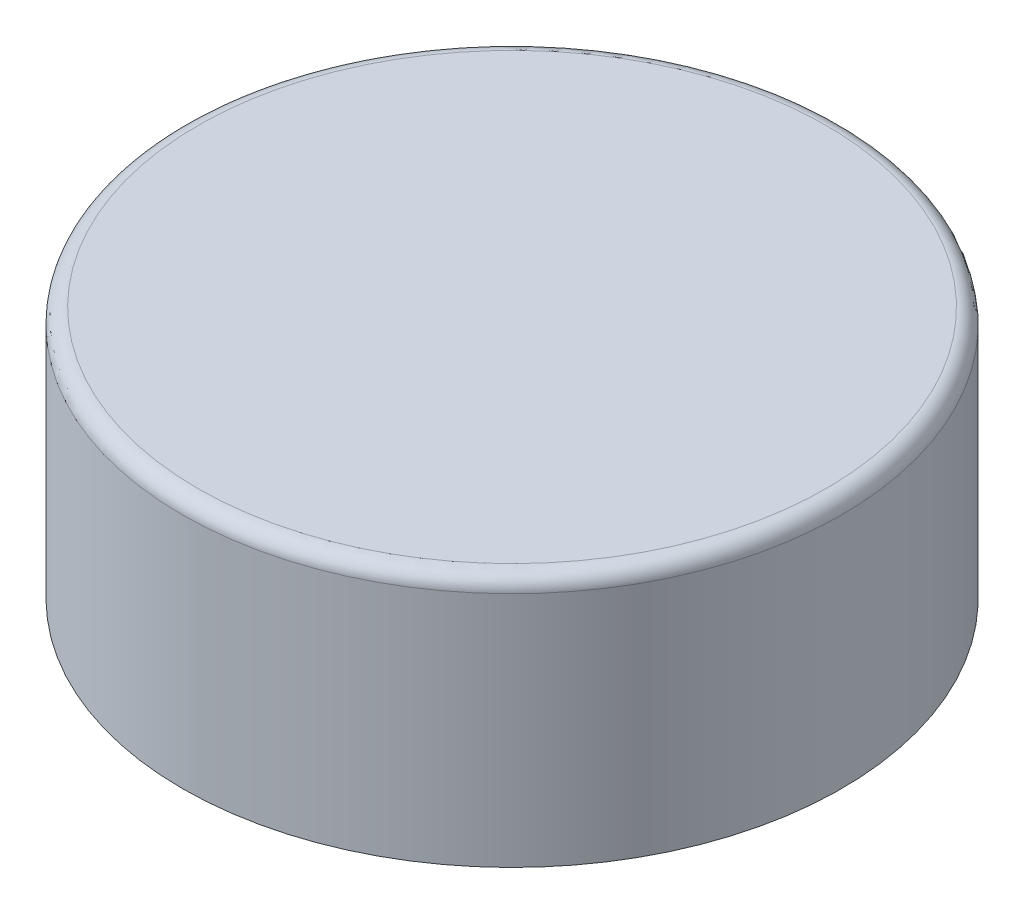
from build123d import *

# Parameters (mm, degrees)
SKETCH1_R           = 43.1
SKETCH1_R_2         = 40.1
BOSS_EXTRUDE1_DEPTH = 33
SKETCH1_2_R         = 40.1
BOSS_EXTRUDE2_DEPTH = 3
FILLET1_R           = 2


with BuildPart() as part:
    # Sketch1 → Boss-Extrude1 (new body)
    with BuildSketch(Plane(origin=(0, 0, 0), x_dir=(1, 0, 0), z_dir=(0, 1, 0))):
        Circle(SKETCH1_R)
        Circle(SKETCH1_R_2, mode=Mode.SUBTRACT)
    extrude(amount=-BOSS_EXTRUDE1_DEPTH)

    # Sketch1_2 → Boss-Extrude2 (add)
    with BuildSketch(Plane(origin=(0, 0, 0), x_dir=(1, 0, 0), z_dir=(0, 1, 0))):
        Circle(SKETCH1_2_R)
    extrude(amount=-BOSS_EXTRUDE2_DEPTH)

    # Fillet1
    fillet1_edges = [part.edges().sort_by_distance(p)[0] for p in [
        (-40.1, -3, 0),
        (-43.1, 0, 0),
    ]]
    fillet(fillet1_edges, radius=FILLET1_R)


solid = part.part
